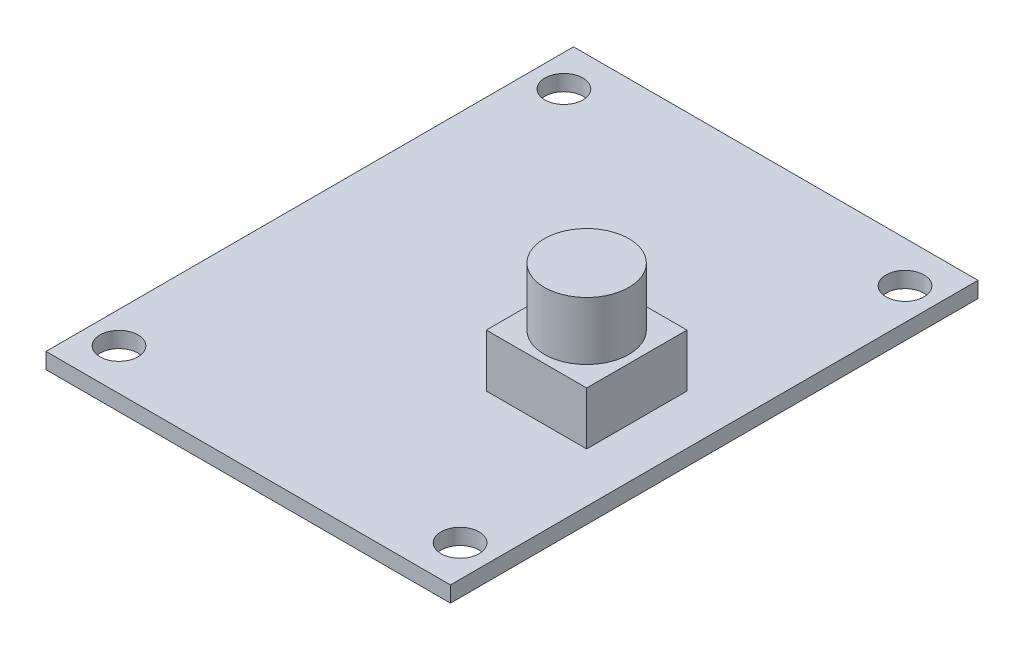
from build123d import *

# Parameters (mm, degrees)
SKETCH1_W           = 38.3
SKETCH1_H           = 49.96
SKETCH1_R           = 1.8
BOSS_EXTRUDE1_DEPTH = 1.5
SKETCH3_W           = 9.5
SKETCH3_H           = 9.5
BOSS_EXTRUDE2_DEPTH = 5
SKETCH5_R           = 4
BOSS_EXTRUDE3_DEPTH = 5.5


with BuildPart() as part:
    # Sketch1 → Boss-Extrude1 (new body)
    with BuildSketch(Plane(origin=(0, 0, 0), x_dir=(1, 0, 0), z_dir=(0, 1, 0))):
        Rectangle(SKETCH1_W, SKETCH1_H)
        with Locations((-16.15, 21.066684073)):
            Circle(SKETCH1_R, mode=Mode.SUBTRACT)
        with Locations((16.15, 21.066684073)):
            Circle(SKETCH1_R, mode=Mode.SUBTRACT)
        with Locations((-16.15, -21.066684073)):
            Circle(SKETCH1_R, mode=Mode.SUBTRACT)
        with Locations((16.15, -21.066684073)):
            Circle(SKETCH1_R, mode=Mode.SUBTRACT)
    extrude(amount=BOSS_EXTRUDE1_DEPTH)


with BuildPart() as body_2:
    # Sketch3 → Boss-Extrude2 (new body)
    with BuildSketch(Plane(origin=(0, 1.5, 0), x_dir=(1, 0, 0), z_dir=(0, 1, 0))):
        with Locations((9.7, -2.63)):
            Rectangle(SKETCH3_W, SKETCH3_H)
    extrude(amount=BOSS_EXTRUDE2_DEPTH)

    # Sketch5 → Boss-Extrude3 (add)
    with BuildSketch(Plane(origin=(0, 6.5, 0), x_dir=(1, 0, 0), z_dir=(0, 1, 0))):
        with Locations((9.7, -2.63)):
            Circle(SKETCH5_R)
    extrude(amount=BOSS_EXTRUDE3_DEPTH)


solid = Compound([part.part, body_2.part])
